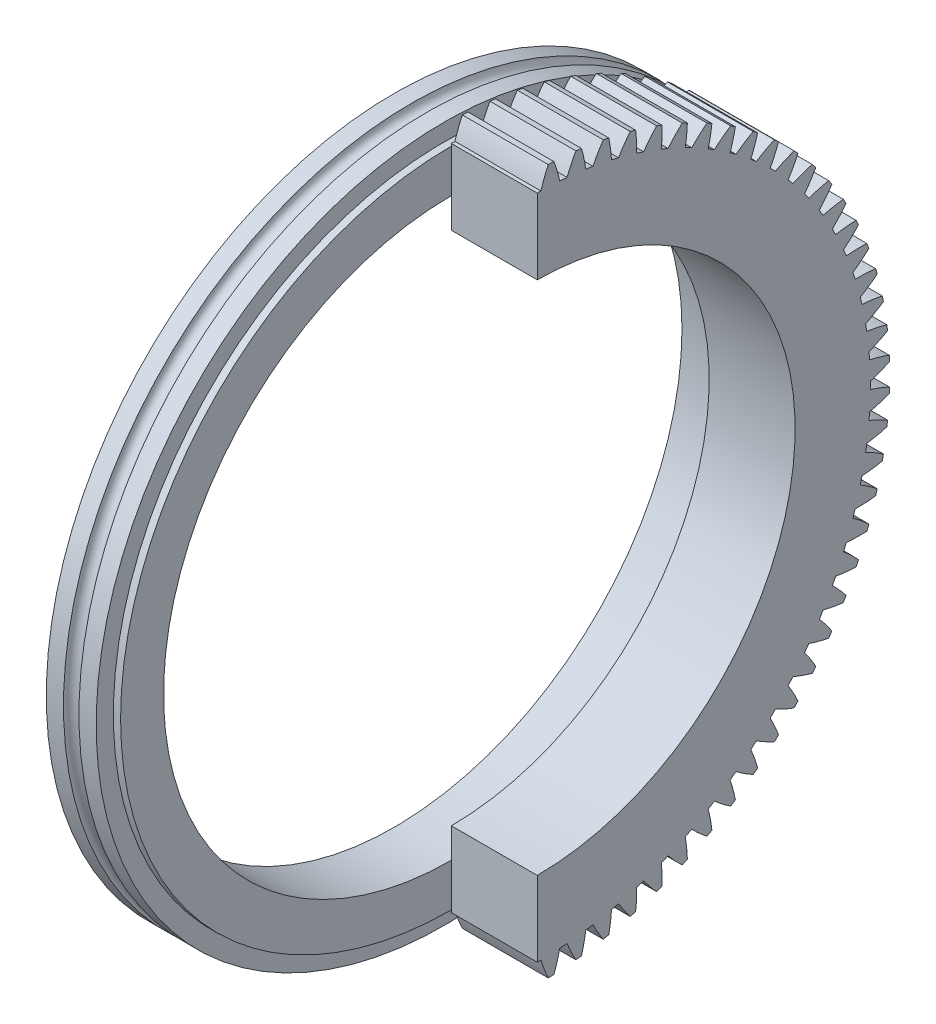
from build123d import *

# Parameters (mm, degrees)
BASPROSKE_W        = 25.4
BASPROSKE_H        = 104.14
TOOTHCUT_DEPTH     = 150.450457343
TEETHCUTS_COUNT    = 80
TEETHCUTS_ANGLE    = 355.5
BORSKE_R           = 0.396875
BORE_DEPTH         = 50.8000508
CUT_EXTRUDE1_REACH = 151.379
SKETCH1_R          = 76.2
CUT_EXTRUDE2_REACH = 151.379
SKETCH2_W          = 138.532303362
SKETCH2_H          = 251.521879629


with BuildPart() as part:
    # BasProSke → Base-Revolve (revolve)
    with BuildSketch(Plane(origin=(0, 0, 0), x_dir=(1, 0, 0), z_dir=(0, 1, 0)), mode=Mode.PRIVATE) as base_revolve_sk:
        with Locations((12.7, 52.07)):
            Rectangle(BASPROSKE_W, BASPROSKE_H)
    revolve(base_revolve_sk.sketch.rotate(Axis((-10, 0, 0), (1, 0, 0)), 180), axis=Axis((-10, 0, 0), (1, 0, 0)))

    # TooCutSke → ToothCut (cut, through all)
    with BuildSketch(Plane(origin=(0, 0, 0), x_dir=(0, 0, -1), z_dir=(1, 0, 0))):
        with BuildLine():
            ThreePointArc((1.077205137, 98.417835051), (0, 98.42373), (-1.077205137, 98.417835051))
            ThreePointArc((-1.077205137, 98.417835051), (-2.067591162, 101.307184691), (-3.272181134, 104.113992277))
            ThreePointArc((-3.272181134, 104.113992277), (0, 104.1654), (3.272181134, 104.113992277))
            ThreePointArc((3.272181134, 104.113992277), (2.067591162, 101.307184691), (1.077205137, 98.417835051))
        make_face()
    toothcut = extrude(amount=TOOTHCUT_DEPTH, mode=Mode.SUBTRACT)

    # TeethCuts: ToothCut ×80 about axis
    teethcuts_axis = Axis((-10, 0, 0), (1, 0, 0))
    for i in range(1, TEETHCUTS_COUNT):
        add(toothcut.rotate(teethcuts_axis, i * TEETHCUTS_ANGLE / (TEETHCUTS_COUNT - 1)), mode=Mode.SUBTRACT)

    # BorSke → Bore (cut, symmetric)
    with BuildSketch(Plane(origin=(0, 0, 0), x_dir=(0, 0, -1), z_dir=(1, 0, 0))):
        with Locations(Location((0, 0, 0), (0, 0, 180))):
            Circle(BORSKE_R)
    extrude(amount=BORE_DEPTH, both=True, mode=Mode.SUBTRACT)

    # Sketch1 → Cut-Extrude1 (cut, up to next)
    with BuildSketch(Plane(origin=(25.4, 0, 0), x_dir=(0, 0, -1), z_dir=(1, 0, 0)), mode=Mode.PRIVATE) as cut_extrude1_sk1:
        Circle(SKETCH1_R)
    cut_extrude1_tool1 = extrude(cut_extrude1_sk1.sketch, amount=-CUT_EXTRUDE1_REACH, mode=Mode.PRIVATE) & part.part
    add(cut_extrude1_tool1.solids().sort_by_distance((25.4, 0, 0))[0], mode=Mode.SUBTRACT)

    # Sketch2 → Cut-Extrude2 (cut, up to next)
    with BuildSketch(Plane(origin=(25.4, 0, 0), x_dir=(0, 0, -1), z_dir=(1, 0, 0)), mode=Mode.PRIVATE) as cut_extrude2_sk1:
        with Locations((-69.266151681, 3.39894432)):
            Rectangle(SKETCH2_W, SKETCH2_H)
    cut_extrude2_tool1 = extrude(cut_extrude2_sk1.sketch, amount=-CUT_EXTRUDE2_REACH, mode=Mode.PRIVATE) & part.part
    add(cut_extrude2_tool1.solids().sort_by_distance((25.4, 3.398944, 69.266152))[0], mode=Mode.SUBTRACT)

    # Sketch4 → Revolve1 (revolve)
    with BuildSketch(Plane(origin=(0, 0, 0), x_dir=(1, 0, 0), z_dir=(0, 1, 0))):
        with BuildLine():
            Line((0, 97.738952184), (-2.140464336, 97.738952184))
            Line((-2.140464336, 97.738952184), (-2.140464336, 102.818952184))
            Line((-2.140464336, 102.818952184), (-7.220464336, 102.818952184))
            ThreePointArc((-7.220464336, 102.818952184), (-9.506464336, 100.532952184), (-11.792464336, 102.818952184))
            Line((-11.792464336, 102.818952184), (-16.872464336, 102.818952184))
            Line((-16.872464336, 102.818952184), (-16.872464336, 97.738952184))
            ThreePointArc((-16.872464336, 97.738952184), (-14.586464336, 95.452952184), (-16.872464336, 93.166952184))
            Line((-16.872464336, 93.166952184), (-16.872464336, 85.038952184))
            Line((-16.872464336, 85.038952184), (0, 85.038952184))
            Line((0, 85.038952184), (0, 97.738952184))
        make_face()
    revolve(axis=Axis((0, 0, 0), (-1, 0, 0)))


solid = part.part
